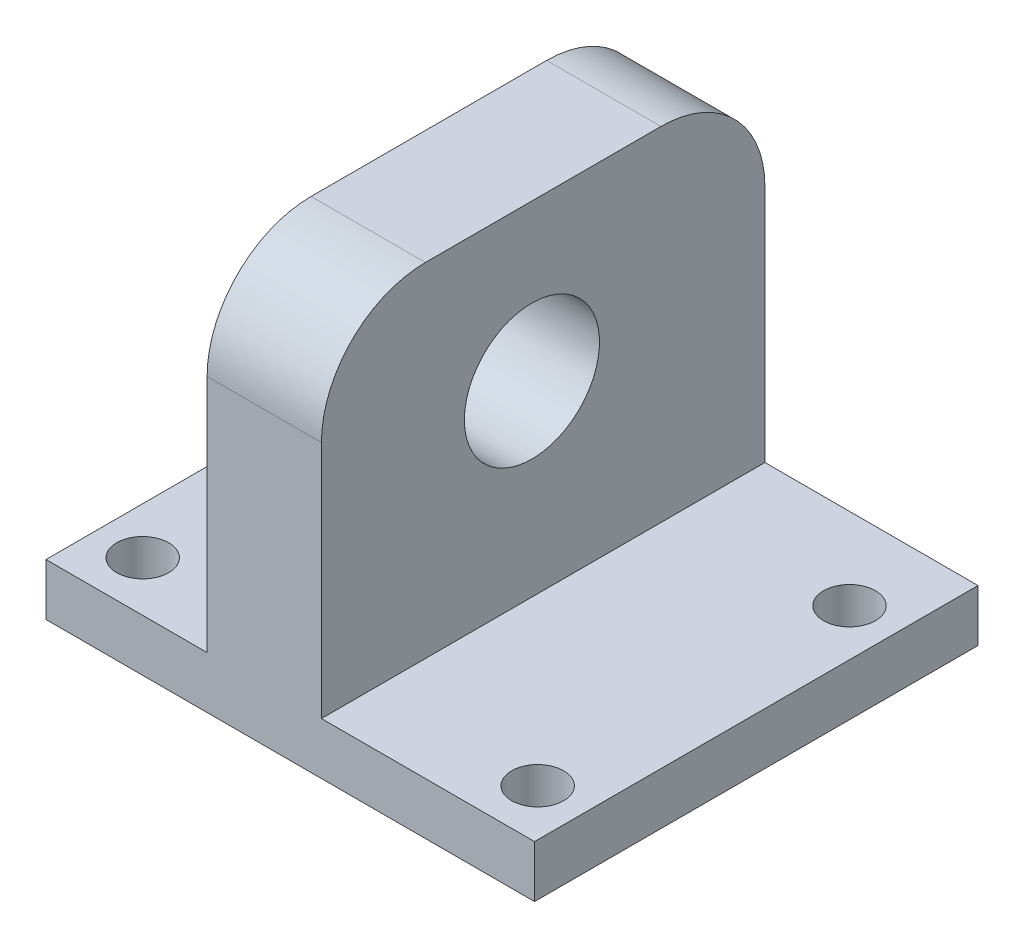
from build123d import *

# Parameters (mm, degrees)
SKETCH_1_W           = 47
SKETCH_1_H           = 42.665281763
SKETCH_1_R           = 2.5
EXTRUDE_1_DEPTH      = 5
SKETCH_2_W           = 6
SKETCH_2_H           = 42.665281763
SKETCH_2_W_2         = 47
SKETCH_2_H_2         = 2
EXTRUDE_2_DEPTH      = 33
SKETCH_3_W           = 40.665281763
SKETCH_3_H           = 33
EXTRUDE_3_DEPTH      = 6
SKETCH_4_R           = 6.5
CUT_EXTRUDE_2_DEPTH  = 7
CHAMFER_1_SIZE       = 3
CUT_EXTRUDE_8_DEPTH  = 25
SKETCH_7_W           = 20.5
SKETCH_7_H           = 8
CUT_EXTRUDE_9_DEPTH  = 10
SKETCH_8_R           = 6.5
EXTRUDE_4_DEPTH      = 5
FILLET_4_R           = 2
SKETCH_9_W           = 11
SKETCH_9_H           = 7.412058926
EXTRUDE_5_DEPTH      = 25
FILLET_5_R           = 10
CUT_EXTRUDE_10_DEPTH = 4


with BuildPart() as part:
    # 草图1 → 凸台-拉伸1 (new body)
    with BuildSketch(Plane(origin=(0, 0, 0), x_dir=(1, 0, 0), z_dir=(0, 1, 0))):
        with Locations((0, 8.371925414)):
            Rectangle(SKETCH_1_W, SKETCH_1_H)
        with Locations((19, -8.15756763)):
            Circle(SKETCH_1_R, mode=Mode.SUBTRACT)
        with Locations((-19, -8.15756763)):
            Circle(SKETCH_1_R, mode=Mode.SUBTRACT)
        with Locations((19, 21.84243237)):
            Circle(SKETCH_1_R, mode=Mode.SUBTRACT)
        with Locations((-19, 21.84243237)):
            Circle(SKETCH_1_R, mode=Mode.SUBTRACT)
    extrude(amount=EXTRUDE_1_DEPTH)

    # 草图2 → 凸台-拉伸2 (add)
    with BuildSketch(Plane(origin=(0, 5, 0), x_dir=(1, 0, 0), z_dir=(0, 1, 0))):
        with Locations((0, 8.371925414)):
            Rectangle(SKETCH_2_W, SKETCH_2_H)
        with Locations((0, 28.704566295)):
            Rectangle(SKETCH_2_W_2, SKETCH_2_H_2)
    extrude(amount=EXTRUDE_2_DEPTH)

    # 草图3 → 凸台-拉伸3 (add)
    with BuildSketch(Plane.ZY.offset(3)):
        with Locations((-7.371925414, 21.5)):
            Rectangle(SKETCH_3_W, SKETCH_3_H)
        with Locations((-7.371925414, 21.5)):
            Rectangle(SKETCH_3_W, SKETCH_3_H)
        with Locations((-7.371925414, 21.5)):
            Rectangle(SKETCH_3_W, SKETCH_3_H)
        with Locations((-7.371925414, 21.5)):
            Rectangle(SKETCH_3_W, SKETCH_3_H)
        with Locations((-7.371925414, 21.5)):
            Rectangle(SKETCH_3_W, SKETCH_3_H)
        with Locations((-7.371925414, 21.5)):
            Rectangle(SKETCH_3_W, SKETCH_3_H)
        with Locations((-7.371925414, 21.5)):
            Rectangle(SKETCH_3_W, SKETCH_3_H)
        with Locations((-7.371925414, 21.5)):
            Rectangle(SKETCH_3_W, SKETCH_3_H)
    extrude(amount=-EXTRUDE_3_DEPTH)

    # 草图4 → 切除-拉伸2 (cut)
    with BuildSketch(Plane(origin=(-3, 2.117173295, 0), x_dir=(0, 0, 1), z_dir=(-1, 0, 0))):
        with Locations((-7.289458503, 20.878429676)):
            Circle(SKETCH_4_R)
    extrude(amount=-CUT_EXTRUDE_2_DEPTH, mode=Mode.SUBTRACT)

    # 倒角1
    chamfer_1_edges = [part.edges().sort_by_distance(p)[0] for p in [
        (23.5, 38, -28.704566295),
        (-23.5, 38, -28.704566295),
    ]]
    chamfer(chamfer_1_edges, length=CHAMFER_1_SIZE)

    # 草图6 → 切除-拉伸8 (cut)
    with BuildSketch(Plane(origin=(0, 38, 0), x_dir=(1, 0, 0), z_dir=(0, 1, 0))):
        Polygon((-26.394551402, 22.292507369), (-3, 22.292507369), (-3, 27.704566295), (-20.5, 27.704566295), (-20.5, 29.704566295), (20.5, 29.704566295), (20.5, 27.704566295), (3, 27.704566295), (3, 22.292507369), (28.987300096, 22.292507369), (28.987300096, 31.415661045), (-26.394551402, 31.415661045), align=None)
        Polygon((-3, 27.704566295), (-3, 22.292507369), (3, 22.292507369), (3, 27.704566295), (20.5, 27.704566295), (20.5, 29.704566295), (-20.5, 29.704566295), (-20.5, 27.704566295), align=None)
    extrude(amount=-CUT_EXTRUDE_8_DEPTH, mode=Mode.SUBTRACT)

    # 草图7 → 切除-拉伸9 (cut)
    with BuildSketch(Plane.XY.offset(-27.704566295)):
        with Locations((13.25, 9)):
            Rectangle(SKETCH_7_W, SKETCH_7_H)
    extrude(amount=-CUT_EXTRUDE_9_DEPTH, mode=Mode.SUBTRACT)

    # 草图8 → 凸台-拉伸4 (add)
    with BuildSketch(Plane.ZY.offset(3)):
        Polygon((12.960715468, 38), (-22.292507369, 38), (-22.292507369, 13), (-27.704566295, 13), (-27.704566295, 5), (12.960715468, 5), align=None)
        with Locations((-7.289458503, 22.995602971)):
            Circle(SKETCH_8_R, mode=Mode.SUBTRACT)
    extrude(amount=EXTRUDE_4_DEPTH)

    # 圆角4
    fillet_4_edges = [part.edges().sort_by_distance(p)[0] for p in [
        (-8, 9, -27.704566295),
    ]]
    fillet(fillet_4_edges, radius=FILLET_4_R)

    # 草图9 → 凸台-拉伸5 (add)
    with BuildSketch(Plane(origin=(0, 13, 0), x_dir=(1, 0, 0), z_dir=(0, 1, 0))):
        with Locations((-2.5, 25.998536832)):
            Rectangle(SKETCH_9_W, SKETCH_9_H)
    extrude(amount=EXTRUDE_5_DEPTH)

    # 圆角5
    fillet_5_edges = [part.edges().sort_by_distance(p)[0] for p in [
        (-2.5, 38, -29.704566295),
        (-2.5, 38, 12.960715468),
    ]]
    fillet(fillet_5_edges, radius=FILLET_5_R)

    # 草图10 → 切除-拉伸10 (cut)
    with BuildSketch(Plane(origin=(0, 0, -29.704566295), x_dir=(-1, 0, 0), z_dir=(0, 0, -1))):
        with BuildLine():
            ThreePointArc((18.603175919, 9), (16.603175919, 11), (14.603175919, 9))
            Line((14.603175919, 9), (18.603175919, 9))
        make_face()
        with BuildLine():
            Line((18.603175919, 9), (14.603175919, 9))
            ThreePointArc((14.603175919, 9), (16.603175919, 7), (18.603175919, 9))
        make_face()
        with BuildLine():
            ThreePointArc((18.603175919, 9), (16.603175919, 11), (14.603175919, 9))
            Line((14.603175919, 9), (18.603175919, 9))
        make_face()
        with BuildLine():
            Line((18.603175919, 9), (14.603175919, 9))
            ThreePointArc((14.603175919, 9), (16.603175919, 7), (18.603175919, 9))
        make_face()
        with BuildLine():
            ThreePointArc((4.5, 14.309411668), (3.914213562, 15.723625231), (2.5, 16.309411668))
            Line((2.5, 16.309411668), (2.5, 12.309411668))
            ThreePointArc((2.5, 12.309411668), (3.914213562, 12.895198106), (4.5, 14.309411668))
        make_face()
        with BuildLine():
            Line((2.5, 12.309411668), (2.5, 16.309411668))
            ThreePointArc((2.5, 16.309411668), (0.5, 14.309411668), (2.5, 12.309411668))
        make_face()
        with BuildLine():
            ThreePointArc((4.5, 14.309411668), (3.914213562, 15.723625231), (2.5, 16.309411668))
            Line((2.5, 16.309411668), (2.5, 12.309411668))
            ThreePointArc((2.5, 12.309411668), (3.914213562, 12.895198106), (4.5, 14.309411668))
        make_face()
        with BuildLine():
            Line((2.5, 12.309411668), (2.5, 16.309411668))
            ThreePointArc((2.5, 16.309411668), (0.5, 14.309411668), (2.5, 12.309411668))
        make_face()
    extrude(amount=-CUT_EXTRUDE_10_DEPTH, mode=Mode.SUBTRACT)


solid = part.part
